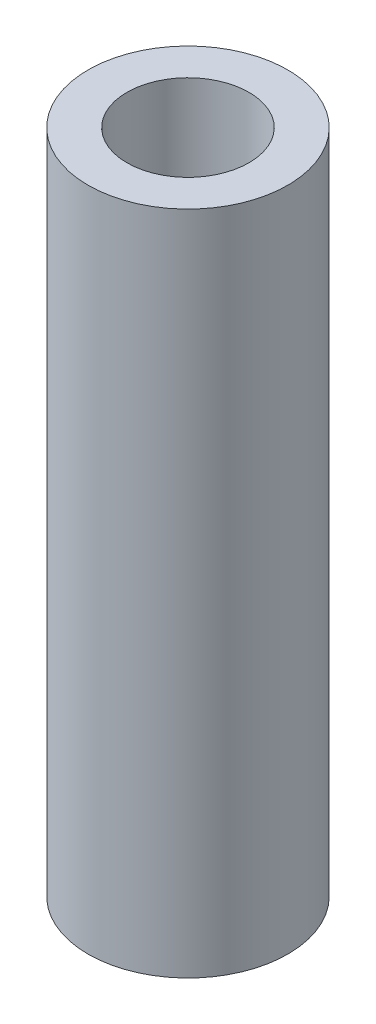
from build123d import *

# Parameters (mm, degrees)
SKETCH2_R           = 4.5
SKETCH2_R_2         = 2.75
BOSS_EXTRUDE1_DEPTH = 30


with BuildPart() as part:
    # Sketch2 → Boss-Extrude1 (new body)
    with BuildSketch(Plane(origin=(0, 0, 0), x_dir=(1, 0, 0), z_dir=(0, 1, 0))):
        Circle(SKETCH2_R)
        Circle(SKETCH2_R_2, mode=Mode.SUBTRACT)
    extrude(amount=BOSS_EXTRUDE1_DEPTH)


solid = part.part
